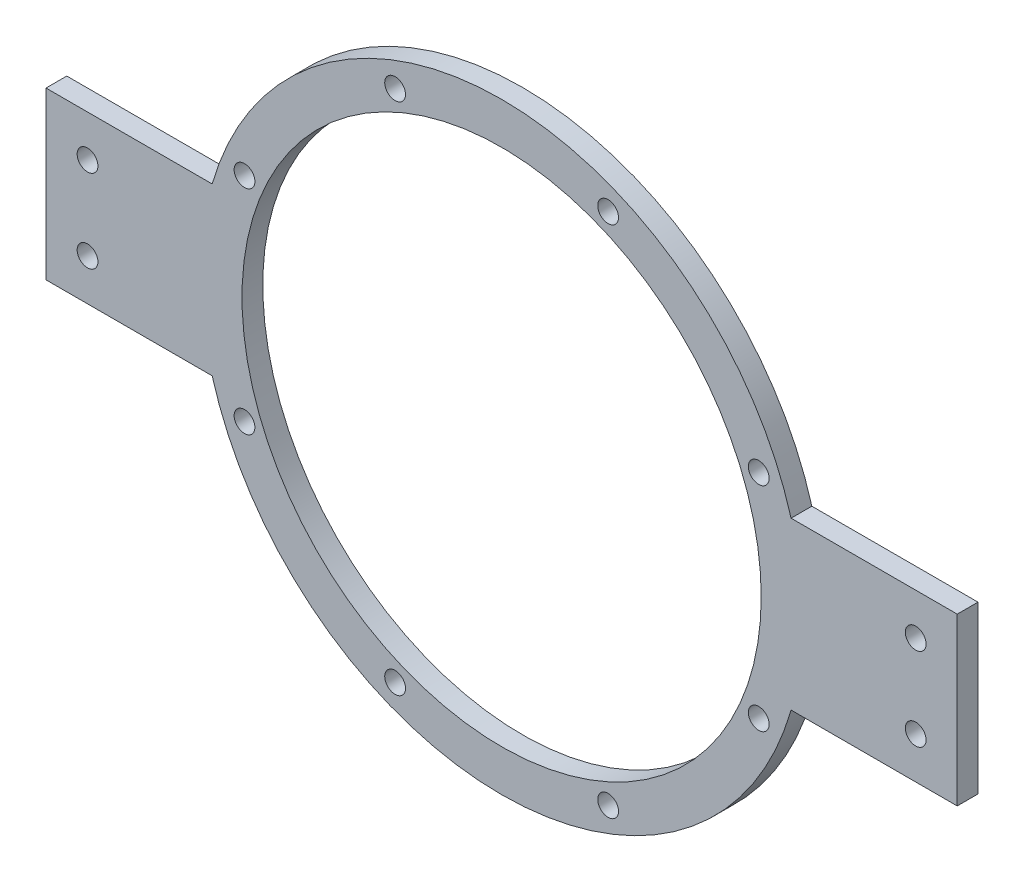
from build123d import *

# Parameters (mm, degrees)
SKETCH1_R           = 79.375
BOSS_EXTRUDE1_DEPTH = 6.35
SKETCH2_R           = 3.175
CUT_EXTRUDE1_DEPTH  = 76.2


with BuildPart() as part:
    # Sketch1 → Boss-Extrude1 (new body)
    with BuildSketch(Plane.XY):
        with BuildLine():
            Line((-139.302235141, 25.4), (-88.502235141, 25.4))
            ThreePointArc((-88.502235141, 25.4), (0, 92.075), (88.502235141, 25.4))
            Line((88.502235141, 25.4), (139.302235141, 25.4))
            Line((139.302235141, 25.4), (139.302235141, -25.4))
            Line((139.302235141, -25.4), (88.502235141, -25.4))
            ThreePointArc((88.502235141, -25.4), (0, -92.075), (-88.502235141, -25.4))
            Line((-88.502235141, -25.4), (-139.302235141, -25.4))
            Line((-139.302235141, -25.4), (-139.302235141, 25.4))
        make_face()
        Circle(SKETCH1_R, mode=Mode.SUBTRACT)
    extrude(amount=BOSS_EXTRUDE1_DEPTH)

    # Sketch2 → Cut-Extrude1 (cut)
    with BuildSketch(Plane.XY.offset(6.35)):
        with Locations((-126.602235141, -12.7)):
            Circle(SKETCH2_R)
        with Locations((-78.612909421, -32.56253326)):
            Circle(SKETCH2_R)
        with Locations((78.612909421, -32.56253326)):
            Circle(SKETCH2_R)
        with Locations((126.602235141, 12.7)):
            Circle(SKETCH2_R)
        with Locations((126.602235141, -12.7)):
            Circle(SKETCH2_R)
        with Locations((78.612909421, 32.56253326)):
            Circle(SKETCH2_R)
        with Locations((32.56253326, 78.612909421)):
            Circle(SKETCH2_R)
        with Locations((-126.602235141, 12.7)):
            Circle(SKETCH2_R)
        with Locations((-32.56253326, -78.612909421)):
            Circle(SKETCH2_R)
        with Locations((32.56253326, -78.612909421)):
            Circle(SKETCH2_R)
        with Locations((-32.56253326, 78.612909421)):
            Circle(SKETCH2_R)
        with Locations((-78.612909421, 32.56253326)):
            Circle(SKETCH2_R)
    extrude(amount=-CUT_EXTRUDE1_DEPTH, mode=Mode.SUBTRACT)


solid = part.part
